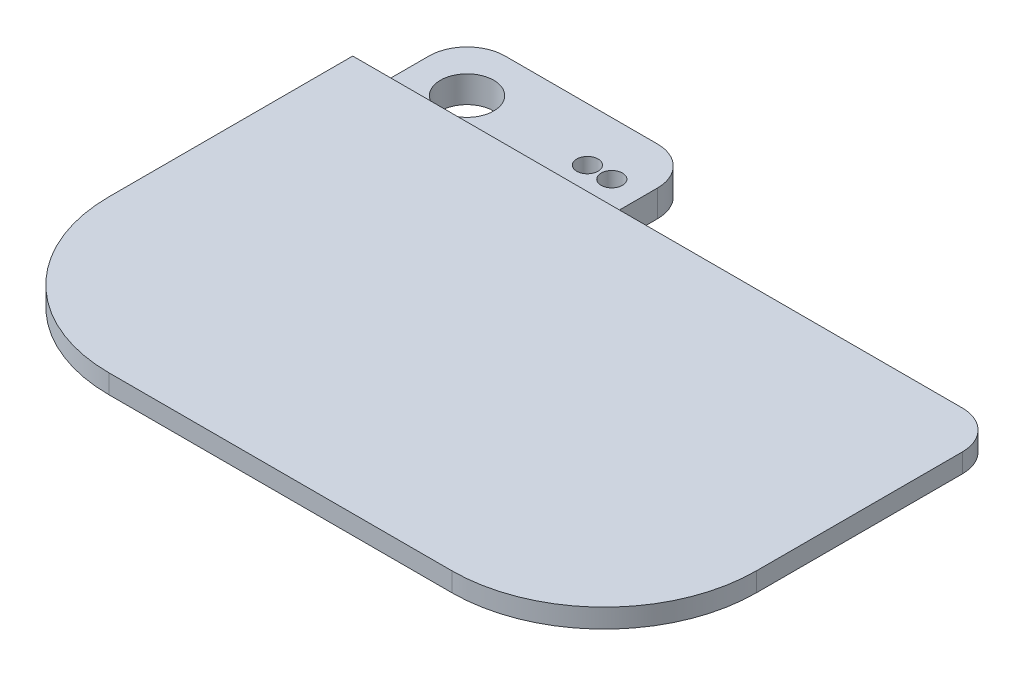
from build123d import *

# Parameters (mm, degrees)
SKETCH1_W           = 107.95
SKETCH1_H           = 85.09
SKETCH1_R           = 4.445
BOSS_EXTRUDE1_DEPTH = 3.175
SKETCH2_W           = 107.95
SKETCH2_H           = 25.4
SKETCH2_R           = 4.445
BOSS_EXTRUDE2_DEPTH = 7.62
SKETCH3_W           = 69.85
SKETCH3_H           = 19.05
CUT_EXTRUDE1_DEPTH  = 11.795
SKETCH4_W           = 38.1
SKETCH4_H           = 19.05
CUT_EXTRUDE2_DEPTH  = 6.35
SKETCH5_R           = 1.778
CUT_EXTRUDE3_DEPTH  = 5.445
SKETCH6_W           = 19.05
SKETCH6_H           = 7.62
CUT_EXTRUDE4_DEPTH  = 26.4
BOSS_EXTRUDE3_DEPTH = 38.1
FILLET1_R           = 25.4
FILLET2_R           = 6.35
FILLET3_R           = 3.175


with BuildPart() as part:
    # Sketch1 → Boss-Extrude1 (new body)
    with BuildSketch(Plane(origin=(0, 0, 0), x_dir=(1, 0, 0), z_dir=(0, 1, 0))):
        with Locations((53.975, 42.545)):
            Rectangle(SKETCH1_W, SKETCH1_H)
        with Locations((8.89, 76.2)):
            Circle(SKETCH1_R, mode=Mode.SUBTRACT)
    extrude(amount=BOSS_EXTRUDE1_DEPTH)

    # Sketch2 → Boss-Extrude2 (add)
    with BuildSketch(Plane.XZ):
        with Locations((53.975, -72.39)):
            Rectangle(SKETCH2_W, SKETCH2_H)
        with Locations((8.89, -76.2)):
            Circle(SKETCH2_R, mode=Mode.SUBTRACT)
    extrude(amount=BOSS_EXTRUDE2_DEPTH)

    # Sketch3 → Cut-Extrude1 (cut, through all)
    with BuildSketch(Plane.XZ.offset(7.62)):
        with Locations((73.025, -75.565)):
            Rectangle(SKETCH3_W, SKETCH3_H)
    extrude(amount=-CUT_EXTRUDE1_DEPTH, mode=Mode.SUBTRACT)

    # Sketch4 → Cut-Extrude2 (cut)
    with BuildSketch(Plane(origin=(0, 3.175, 0), x_dir=(1, 0, 0), z_dir=(0, 1, 0))):
        with Locations((19.05, 75.565)):
            Rectangle(SKETCH4_W, SKETCH4_H)
    extrude(amount=-CUT_EXTRUDE2_DEPTH, mode=Mode.SUBTRACT)

    # Sketch5 → Cut-Extrude3 (cut, through all)
    with BuildSketch(Plane(origin=(0, -3.175, 0), x_dir=(1, 0, 0), z_dir=(0, 1, 0))):
        with Locations((28.956, 76.2)):
            Circle(SKETCH5_R)
        with Locations((33.02, 76.2)):
            Circle(SKETCH5_R)
    extrude(amount=-CUT_EXTRUDE3_DEPTH, mode=Mode.SUBTRACT)

    # Sketch6 → Cut-Extrude4 (cut, through all)
    with BuildSketch(Plane.XY.offset(-59.69)):
        with Locations((98.425, -3.81)):
            Rectangle(SKETCH6_W, SKETCH6_H)
    extrude(amount=-CUT_EXTRUDE4_DEPTH, mode=Mode.SUBTRACT)

    # Sketch7 → Boss-Extrude3 (add)
    with BuildSketch(Plane.ZY):
        Polygon((-66.04, 3.175), (-71.12, -3.175), (-66.04, -3.175), align=None)
    extrude(amount=-BOSS_EXTRUDE3_DEPTH)

    # Fillet1
    fillet1_edges = [part.edges().sort_by_distance(p)[0] for p in [
        (107.95, 1.5875, 0),
        (0, 1.5875, 0),
    ]]
    fillet(fillet1_edges, radius=FILLET1_R)

    # Fillet2
    fillet2_edges = [part.edges().sort_by_distance(p)[0] for p in [
        (107.95, 1.5875, -66.04),
        (38.1, -5.3975, -85.09),
        (0, -5.3975, -85.09),
    ]]
    fillet(fillet2_edges, radius=FILLET2_R)

    # Fillet3
    fillet3_edges = [part.edges().sort_by_distance(p)[0] for p in [
        (88.9, -7.62, -62.865),
        (88.9, 0, -62.865),
    ]]
    fillet(fillet3_edges, radius=FILLET3_R)


solid = part.part
